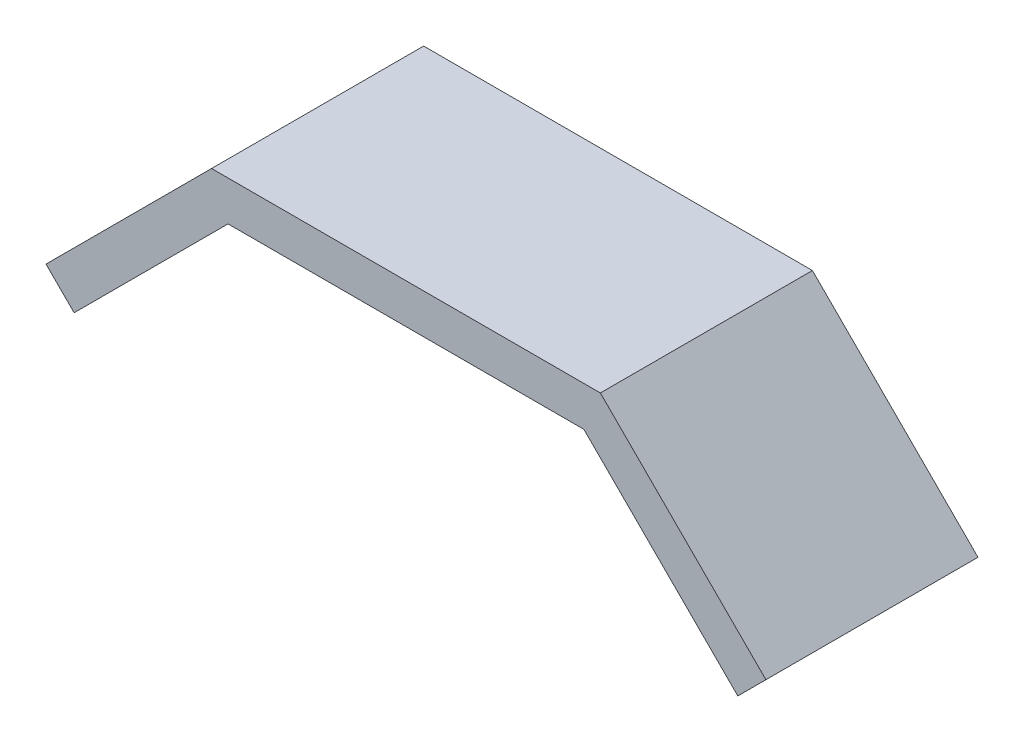
from build123d import *

# Parameters (mm, degrees)
EXTRUDE_THIN1_DEPTH = 24


with BuildPart() as part:
    # Sketch1 → Extrude-Thin1 (new body, symmetric)
    with BuildSketch(Plane.XY):
        Polygon((-81.476659403, -37.476659403), (-44, 0), (44, 0), (81.476659403, -37.476659403), (75.112698372, -43.840620434), (40.272077939, -9), (-40.272077939, -9), (-75.112698372, -43.840620434), align=None)
    extrude(amount=EXTRUDE_THIN1_DEPTH, both=True)


solid = part.part
